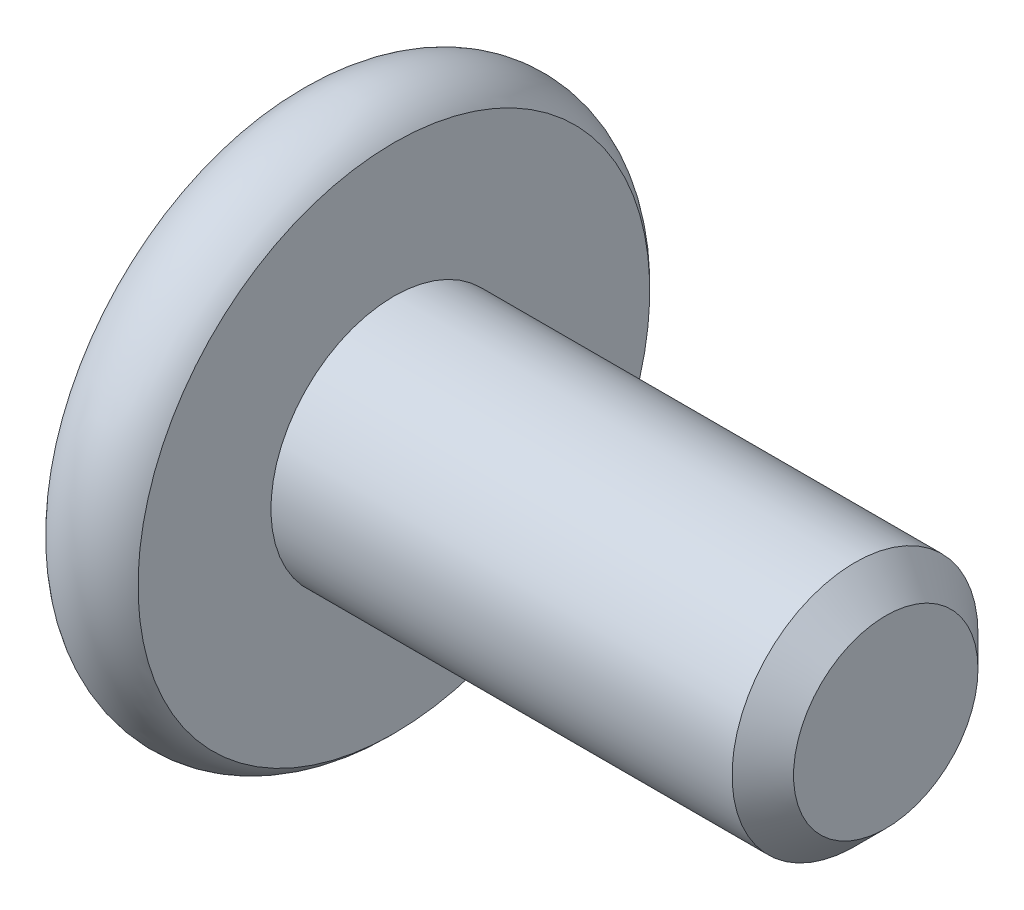
from build123d import *

# Parameters (mm, degrees)
SKETCH2_R           = 2
BOSS_EXTRUDE1_DEPTH = 8
CHAMFER1_SIZE       = 0.5
CUT_EXTRUDE1_DEPTH  = 2.3
SKETCH8_R           = 1.782050808
CUT_EXTRUDE2_DEPTH  = 1
CUT_EXTRUDE2_TAPER  = 45


with BuildPart() as part:
    # Sketch2 → Boss-Extrude1 (new body)
    with BuildSketch(Plane(origin=(0, 0, 0), x_dir=(0, 0, -1), z_dir=(1, 0, 0))):
        Circle(SKETCH2_R)
    extrude(amount=-BOSS_EXTRUDE1_DEPTH)

    # Chamfer1
    chamfer1_edges = [part.edges().sort_by_distance(p)[0] for p in [
        (0, 0, 2),
    ]]
    chamfer(chamfer1_edges, length=CHAMFER1_SIZE)

    # Sketch6 → Revolve1 (revolve)
    with BuildSketch(Plane.XY):
        with BuildLine():
            Line((-9.5, 0), (-9.5, 4.161437828))
            ThreePointArc((-9.5, 4.161437828), (-8.75, 4.5), (-8, 4.161437828))
            Line((-8, 4.161437828), (-8, 0))
            Line((-8, 0), (-9.5, 0))
        make_face()
    revolve(axis=Axis((-8, 0, 0), (-1, 0, 0)))

    # Sketch7 → Cut-Extrude1 (cut)
    with BuildSketch(Plane.ZY.offset(9.5)):
        Polygon((0, 1.732050808), (-1.5, 0.866025404), (-1.5, -0.866025404), (0, -1.732050808), (1.5, -0.866025404), (1.5, 0.866025404), align=None)
    extrude(amount=-CUT_EXTRUDE1_DEPTH, mode=Mode.SUBTRACT)

    # Sketch8 → Cut-Extrude2 (cut)
    with BuildSketch(Plane.ZY.offset(9.5)):
        Circle(SKETCH8_R)
    extrude(amount=-CUT_EXTRUDE2_DEPTH, taper=CUT_EXTRUDE2_TAPER, mode=Mode.SUBTRACT)


solid = part.part
